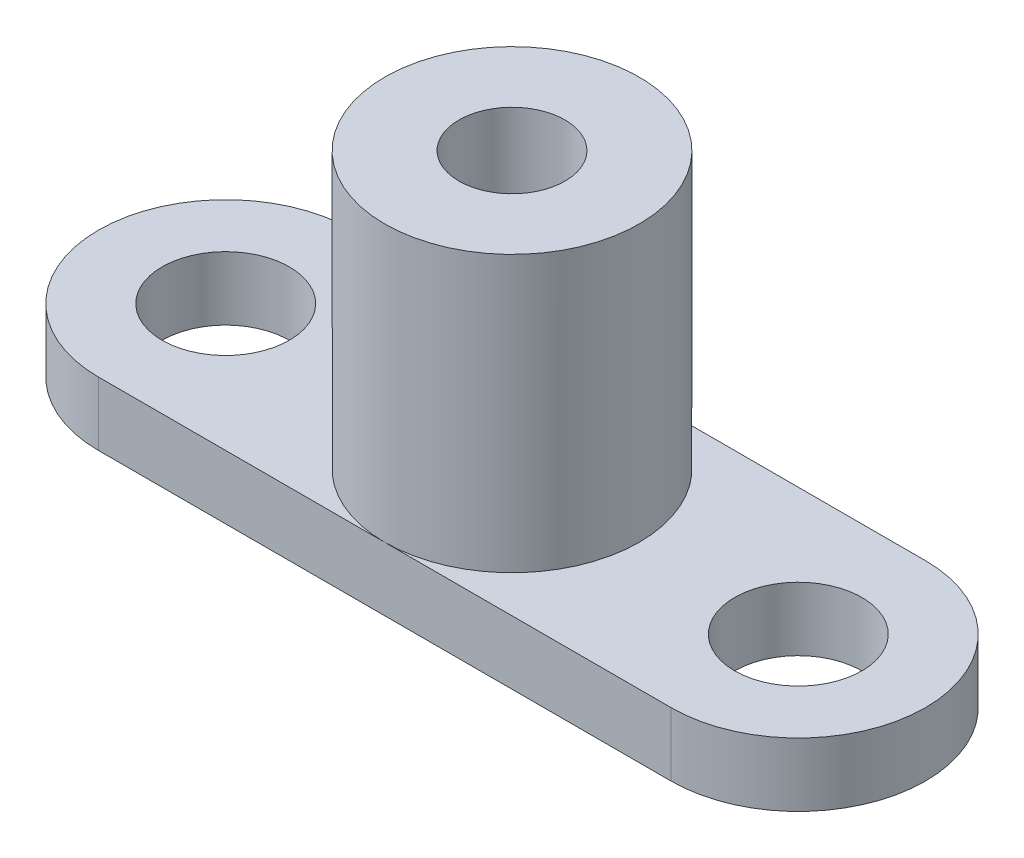
from build123d import *

# Parameters (mm, degrees)
SKETCH_1_R          = 6
EXTRUDE_1_DEPTH     = 3
SKETCH_2_R          = 6
EXTRUDE_2_DEPTH     = 13
HOLE_WIZARD_M6_1_D  = 5
SKETCH_6_R          = 3
CUT_EXTRUDE_1_DEPTH = 10


with BuildPart() as part:
    # 草图1 → 凸台-拉伸1 (new body)
    with BuildSketch(Plane(origin=(0, 0, 0), x_dir=(1, 0, 0), z_dir=(0, 1, 0))):
        with Locations((-13.5, 0)):
            Circle(SKETCH_1_R)
        with BuildLine():
            Line((13.5, 6), (-13.5, 6))
            ThreePointArc((-13.5, 6), (-9.257359313, 4.242640687), (-7.5, 0))
            ThreePointArc((-7.5, 0), (-9.257359313, -4.242640687), (-13.5, -6))
            Line((-13.5, -6), (13.5, -6))
            ThreePointArc((13.5, -6), (7.5, 0), (13.5, 6))
        make_face()
        with Locations((13.5, 0)):
            Circle(SKETCH_1_R)
        with BuildLine():
            Line((-13.5, -6), (-13.5, 6))
            ThreePointArc((-13.5, 6), (-19.5, 0), (-13.5, -6))
        make_face()
        with BuildLine():
            ThreePointArc((19.5, 0), (17.742640687, 4.242640687), (13.5, 6))
            Line((13.5, 6), (13.5, -6))
            ThreePointArc((13.5, -6), (17.742640687, -4.242640687), (19.5, 0))
        make_face()
    extrude(amount=EXTRUDE_1_DEPTH)

    # 草图2 → 凸台-拉伸2 (add)
    with BuildSketch(Plane(origin=(0, 3, 0), x_dir=(1, 0, 0), z_dir=(0, 1, 0))):
        Circle(SKETCH_2_R)
    extrude(amount=EXTRUDE_2_DEPTH)

    # M6 螺纹孔1 (through all)
    with Locations(Plane(origin=(0, 16, 0), x_dir=(1, 0, 0), z_dir=(0, 1, 0))):
        with Locations((0, 0)):
            Hole(HOLE_WIZARD_M6_1_D / 2)

    # 草图6 → 切除-拉伸1 (cut)
    with BuildSketch(Plane(origin=(0, 3, 0), x_dir=(1, 0, 0), z_dir=(0, 1, 0))):
        with Locations((-13.5, 0)):
            Circle(SKETCH_6_R)
        with Locations((13.5, 0)):
            Circle(SKETCH_6_R)
    extrude(amount=-CUT_EXTRUDE_1_DEPTH, mode=Mode.SUBTRACT)


solid = part.part
